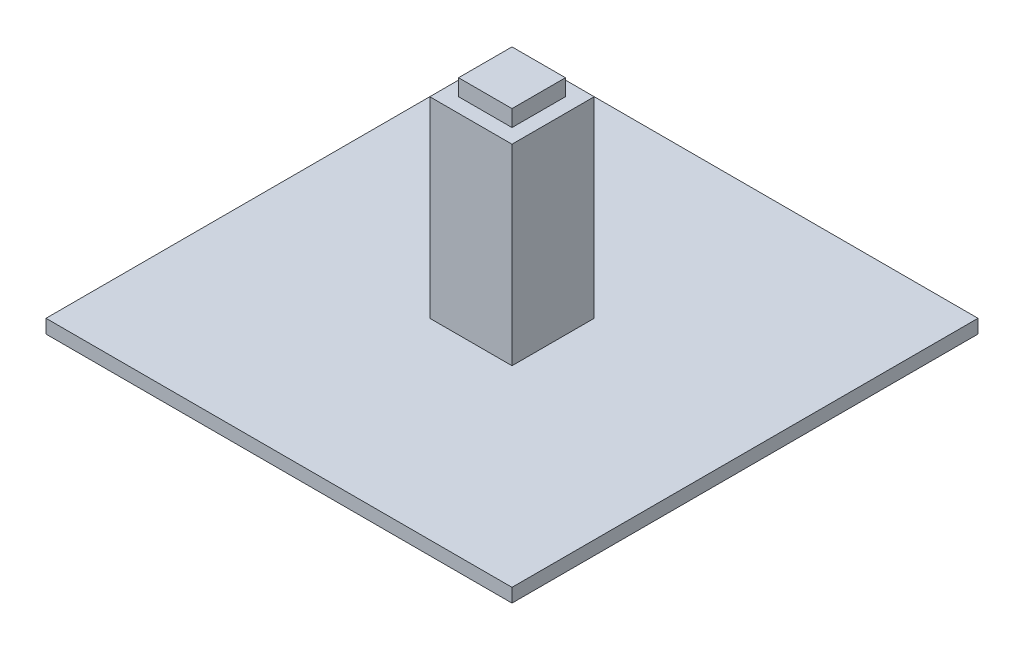
from build123d import *

# Parameters (mm, degrees)
SKETCH1_W           = 170
SKETCH1_H           = 170
BOSS_EXTRUDE1_DEPTH = 5
SKETCH2_W           = 30
SKETCH2_H           = 30
BOSS_EXTRUDE2_DEPTH = 70
SKETCH3_W           = 19.5
SKETCH3_H           = 19.5
BOSS_EXTRUDE3_DEPTH = 6


with BuildPart() as part:
    # Sketch1 → Boss-Extrude1 (new body)
    with BuildSketch(Plane(origin=(0, 0, 0), x_dir=(1, 0, 0), z_dir=(0, 1, 0))):
        Rectangle(SKETCH1_W, SKETCH1_H)
    extrude(amount=BOSS_EXTRUDE1_DEPTH)

    # Sketch2 → Boss-Extrude2 (add)
    with BuildSketch(Plane(origin=(0, 5, 0), x_dir=(1, 0, 0), z_dir=(0, 1, 0))):
        Rectangle(SKETCH2_W, SKETCH2_H)
    extrude(amount=BOSS_EXTRUDE2_DEPTH)

    # Sketch3 → Boss-Extrude3 (add)
    with BuildSketch(Plane(origin=(0, 75, 0), x_dir=(1, 0, 0), z_dir=(0, 1, 0))):
        Rectangle(SKETCH3_W, SKETCH3_H)
    extrude(amount=BOSS_EXTRUDE3_DEPTH)


solid = part.part
